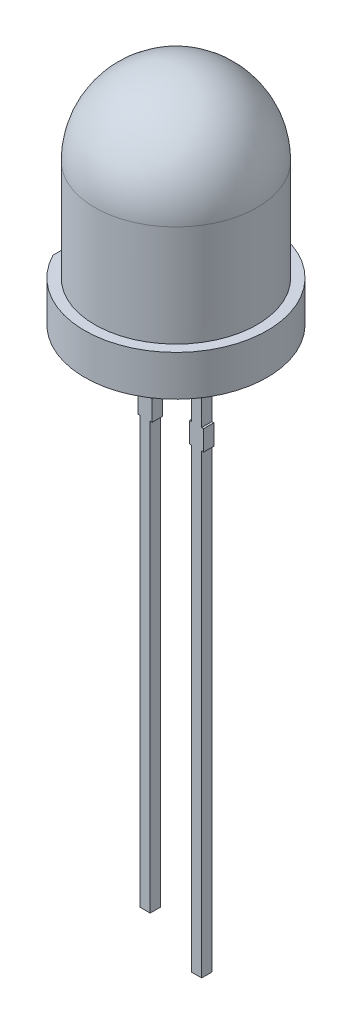
from build123d import *

# Parameters (mm, degrees)
EXTRUDE2_DEPTH     = 2
SKETCH3_3_W        = 0.5
SKETCH3_3_H        = 3.5
SKETCH3_3_H_2      = 1
SKETCH3_3_H_3      = 21
SKETCH3_3_W_2      = 0.1
SKETCH3_3_H_4      = 22.5
EXTRUDE4_DEPTH     = 0.25
CUT_EXTRUDE1_DEPTH = 0.01


with BuildPart() as part:
    # Sketch2 → Extrude2 (new body)
    with BuildSketch(Plane(origin=(0, 0, 0), x_dir=(1, 0, 0), z_dir=(0, 1, 0))):
        with BuildLine():
            ThreePointArc((4.5, 0), (1.060660172, 4.373213921), (-4, 2.061552813))
            Line((-4, 2.061552813), (-4, -2.061552813))
            ThreePointArc((-4, -2.061552813), (1.060660172, -4.373213921), (4.5, 0))
        make_face()
    extrude(amount=EXTRUDE2_DEPTH)

    # Sketch3 → Revolve1 (revolve)
    with BuildSketch(Plane.XY, mode=Mode.PRIVATE) as revolve1_sk:
        with BuildLine():
            Line((0, 11), (0, 2))
            Line((0, 2), (4, 2))
            Line((4, 2), (4, 7))
            ThreePointArc((4, 7), (2.828427125, 9.828427125), (0, 11))
        make_face()
    revolve(revolve1_sk.sketch.rotate(Axis((0, 2, 0), (0, 1, 0)), 180), axis=Axis((0, 2, 0), (0, 1, 0)))  # turned: the seam where the file's is

    # Sketch3_3 → Extrude4 (add, symmetric)
    with BuildSketch(Plane.XY):
        with Locations((-1.27, -1.75)):
            Rectangle(SKETCH3_3_W, SKETCH3_3_H)
        with Locations((-1.27, -4)):
            Rectangle(SKETCH3_3_W, SKETCH3_3_H_2)
        with Locations((-1.27, -15)):
            Rectangle(SKETCH3_3_W, SKETCH3_3_H_3)
        with Locations((-0.97, -4)):
            Rectangle(SKETCH3_3_W_2, SKETCH3_3_H_2)
        with Locations((-1.57, -4)):
            Rectangle(SKETCH3_3_W_2, SKETCH3_3_H_2)
        with Locations((1.27, -1.75)):
            Rectangle(SKETCH3_3_W, SKETCH3_3_H)
        with Locations((1.27, -4)):
            Rectangle(SKETCH3_3_W, SKETCH3_3_H_2)
        with Locations((0.97, -4)):
            Rectangle(SKETCH3_3_W_2, SKETCH3_3_H_2)
        with Locations((1.57, -4)):
            Rectangle(SKETCH3_3_W_2, SKETCH3_3_H_2)
        with Locations((1.27, -15.75)):
            Rectangle(SKETCH3_3_W, SKETCH3_3_H_4)
    extrude(amount=EXTRUDE4_DEPTH, both=True)

    # Sketch5 → Cut-Extrude1 (cut)
    with BuildSketch(Plane.XZ):
        Polygon((-0.452420052, 0.048021614), (-0.47417486, -0.025055309), (-0.490430869, -0.025055309), (-0.502660437, 0.025876182), (-0.516542648, -0.025055309), (-0.532708513, -0.025055309), (-0.554343129, 0.048021614), (-0.535593129, 0.048021614), (-0.524625581, -0.004802905), (-0.511554667, 0.048021614), (-0.493375581, 0.048021614), (-0.481957312, -0.004802905), (-0.471260196, 0.048021614), align=None)
        Polygon((-0.352420052, 0.048021614), (-0.37417486, -0.025055309), (-0.390430869, -0.025055309), (-0.402660437, 0.025876182), (-0.416542648, -0.025055309), (-0.432708513, -0.025055309), (-0.454343129, 0.048021614), (-0.435593129, 0.048021614), (-0.424625581, -0.004802905), (-0.411554667, 0.048021614), (-0.393375581, 0.048021614), (-0.381957312, -0.004802905), (-0.371260196, 0.048021614), align=None)
        Polygon((-0.252420052, 0.048021614), (-0.27417486, -0.025055309), (-0.290430869, -0.025055309), (-0.302660437, 0.025876182), (-0.316542648, -0.025055309), (-0.332708513, -0.025055309), (-0.354343129, 0.048021614), (-0.335593129, 0.048021614), (-0.324625581, -0.004802905), (-0.311554667, 0.048021614), (-0.293375581, 0.048021614), (-0.281957312, -0.004802905), (-0.271260196, 0.048021614), align=None)
        with BuildLine():
            add(Edge.make_bspline(
                [(-0.212035437, -0.012555309), (-0.21208492, -0.013262166), (-0.212187706, -0.014730447), (-0.212956, -0.016874826), (-0.214094784, -0.018983863), (-0.215732268, -0.020904006), (-0.217829848, -0.022583896), (-0.220340975, -0.023963628), (-0.223281261, -0.024900598), (-0.225379574, -0.025002772), (-0.226458513, -0.025055309)],
                knots=[0, 0, 0, 0, 0.803957419, 1.669978378, 2.568830098, 3.52434643, 4.522321038, 5.61514242, 6.773720829, 8, 8, 8, 8], degree=3))
            add(Edge.make_bspline(
                [(-0.226458513, -0.025055309), (-0.227295736, -0.025011774), (-0.228974504, -0.02492448), (-0.231369549, -0.024136875), (-0.233543605, -0.022973736), (-0.235415737, -0.021424559), (-0.23687457, -0.0195154), (-0.238084154, -0.017418687), (-0.238823189, -0.015046255), (-0.238913083, -0.013391561), (-0.238958513, -0.012555309)],
                knots=[0, 0, 0, 0, 1.021956945, 2.049191568, 3.052757421, 4.027239216, 4.995768388, 5.977850542, 6.978043055, 8, 8, 8, 8], degree=3))
            add(Edge.make_bspline(
                [(-0.238958513, -0.012555309), (-0.238915219, -0.011718138), (-0.238830047, -0.010071215), (-0.238068233, -0.007725366), (-0.236922057, -0.005616645), (-0.235421881, -0.003749514), (-0.233582941, -0.002149972), (-0.231367358, -0.001022273), (-0.228981648, -0.000175477), (-0.227297097, -9.5248e-05), (-0.226458513, -5.5309e-05)],
                knots=[0, 0, 0, 0, 1.02256761, 2.011643391, 2.988402578, 3.947919371, 4.930894396, 5.945859716, 6.97743239, 8, 8, 8, 8], degree=3))
            add(Edge.make_bspline(
                [(-0.226458513, -5.5309e-05), (-0.225407874, -0.000105392), (-0.223333207, -0.000204291), (-0.220436843, -0.001211105), (-0.217835951, -0.002501965), (-0.2157626, -0.004261522), (-0.214091645, -0.00616548), (-0.212920275, -0.008245116), (-0.212192959, -0.010395053), (-0.212086927, -0.011849177), (-0.212035437, -0.012555309)],
                knots=[0, 0, 0, 0, 1.193718436, 2.357200027, 3.46616707, 4.488721408, 5.436751473, 6.342315378, 7.195018269, 8, 8, 8, 8], degree=3))
        make_face()
        with BuildLine():
            add(Edge.make_bspline(
                [(-0.151698898, -0.026978386), (-0.153413167, -0.026955925), (-0.156728772, -0.026912483), (-0.161533335, -0.026397716), (-0.166014281, -0.025688356), (-0.170154861, -0.024595527), (-0.173959709, -0.023220375), (-0.17743498, -0.021541535), (-0.180652214, -0.019674828), (-0.183508823, -0.017451603), (-0.186067786, -0.015034575), (-0.188287436, -0.012370522), (-0.190222924, -0.009528525), (-0.191813015, -0.006401934), (-0.193053627, -0.002961141), (-0.193933091, 0.000862934), (-0.194544404, 0.005074496), (-0.194665015, 0.008025352), (-0.194727744, 0.009560076)],
                knots=[0, 0, 0, 0, 1.28338536, 2.482222902, 3.615641418, 4.678302996, 5.684574369, 6.640891817, 7.565949061, 8.464746586, 9.345581526, 10.197575617, 11.056903422, 11.91580542, 12.817603529, 13.789275343, 14.850214295, 16, 16, 16, 16], degree=3))
            Line((-0.194727744, 0.009560076), (-0.175707312, 0.009560076))
            add(Edge.make_bspline(
                [(-0.175707312, 0.009560076), (-0.175585191, 0.00833566), (-0.17535482, 0.006025895), (-0.1747581, 0.002809491), (-0.174006085, 3.4372e-05), (-0.172988015, -0.002292557), (-0.171830096, -0.004277646), (-0.17053807, -0.006010276), (-0.169182565, -0.00757185), (-0.167200639, -0.009343817), (-0.164429187, -0.011107943), (-0.160714991, -0.012570541), (-0.156621271, -0.013372196), (-0.153775677, -0.013467447), (-0.15229986, -0.013516847)],
                knots=[0, 0, 0, 0, 1.193967772, 2.252326225, 3.172507138, 3.978093684, 4.710151129, 5.398551009, 6.073569162, 6.713873795, 7.973381569, 9.239028936, 10.568070259, 12, 12, 12, 12], degree=3))
            add(Edge.make_bspline(
                [(-0.15229986, -0.013516847), (-0.150733021, -0.013472719), (-0.147766038, -0.013389158), (-0.143584285, -0.012560669), (-0.139942179, -0.011270051), (-0.136876202, -0.009450885), (-0.13443239, -0.007203356), (-0.13259409, -0.004598186), (-0.131448613, -0.00157605), (-0.131328354, 0.000575561), (-0.131266206, 0.00168748)],
                knots=[0, 0, 0, 0, 1.292881893, 2.448216373, 3.505729005, 4.47062867, 5.372299035, 6.228402631, 7.084466243, 8, 8, 8, 8], degree=3))
            add(Edge.make_bspline(
                [(-0.131266206, 0.00168748), (-0.13131971, 0.002807024), (-0.131419031, 0.004885282), (-0.132257529, 0.007330253), (-0.133305602, 0.008952137), (-0.13429607, 0.010086044), (-0.135527892, 0.011158151), (-0.137010698, 0.0121395), (-0.13875981, 0.013072394), (-0.140758987, 0.014004298), (-0.143064778, 0.014867152), (-0.145655772, 0.015704135), (-0.14856173, 0.016528433), (-0.151770701, 0.017462566), (-0.155354627, 0.01829539), (-0.157849184, 0.018893448), (-0.159150821, 0.019205509)],
                knots=[0, 0, 0, 0, 1.308217091, 2.428499093, 2.971811445, 3.562083625, 4.185450824, 4.878313926, 5.639298351, 6.505129032, 7.459166185, 8.51991211, 9.692741175, 10.996059842, 12.432571982, 14, 14, 14, 14], degree=3))
            add(Edge.make_bspline(
                [(-0.159150821, 0.019205509), (-0.160434916, 0.019517892), (-0.162923518, 0.020123298), (-0.166538646, 0.021145274), (-0.16990111, 0.022285748), (-0.173053637, 0.02347522), (-0.175944419, 0.024800582), (-0.178595499, 0.026230563), (-0.180971013, 0.027798133), (-0.183098078, 0.029449077), (-0.184954397, 0.031240034), (-0.186557798, 0.033174297), (-0.187915436, 0.035247743), (-0.189013762, 0.03747798), (-0.189850499, 0.039860473), (-0.190451668, 0.042408203), (-0.19081621, 0.04511641), (-0.190859464, 0.046978797), (-0.19088159, 0.04793147)],
                knots=[0, 0, 0, 0, 1.350138021, 2.616595417, 3.836558268, 4.976793827, 6.057431512, 7.083186274, 8.051004732, 8.961973241, 9.830394181, 10.680720399, 11.523687559, 12.356594861, 13.21427804, 14.097880016, 15.027001965, 16, 16, 16, 16], degree=3))
            add(Edge.make_bspline(
                [(-0.19088159, 0.04793147), (-0.190842157, 0.048964648), (-0.190764395, 0.051002064), (-0.190291881, 0.053995248), (-0.189427661, 0.056853586), (-0.188256929, 0.059584082), (-0.186790457, 0.062168959), (-0.185017518, 0.064562502), (-0.183012479, 0.06678559), (-0.180732718, 0.068816516), (-0.178209425, 0.070636258), (-0.17546477, 0.072278331), (-0.172464942, 0.073651759), (-0.169251563, 0.074824306), (-0.165834335, 0.07575158), (-0.162246308, 0.076407135), (-0.158509007, 0.076808345), (-0.155966743, 0.076847734), (-0.154673658, 0.076867768)],
                knots=[0, 0, 0, 0, 0.957814223, 1.888799201, 2.799332819, 3.718439235, 4.637311203, 5.547134667, 6.473851604, 7.407471124, 8.371205588, 9.353539842, 10.366965553, 11.424217362, 12.520959394, 13.644407811, 14.801862002, 16, 16, 16, 16], degree=3))
            add(Edge.make_bspline(
                [(-0.154673658, 0.076867768), (-0.153220801, 0.076833322), (-0.150369959, 0.076765731), (-0.146174857, 0.076399734), (-0.142176274, 0.075651708), (-0.138343346, 0.074705992), (-0.13472451, 0.073480535), (-0.131328822, 0.072007379), (-0.128197886, 0.070266279), (-0.125346485, 0.068272367), (-0.122751207, 0.066122146), (-0.120477296, 0.063775803), (-0.118578546, 0.061230281), (-0.116980115, 0.058506658), (-0.115676946, 0.055491026), (-0.114777074, 0.052078406), (-0.1141769, 0.048261336), (-0.114033588, 0.045580047), (-0.113958513, 0.044175461)],
                knots=[0, 0, 0, 0, 1.186950675, 2.32907279, 3.434719709, 4.506181443, 5.551366779, 6.551492465, 7.525684865, 8.472032948, 9.389619293, 10.274870494, 11.133875947, 11.977154569, 12.849419986, 13.808029842, 14.851741326, 16, 16, 16, 16], degree=3))
            Line((-0.113958513, 0.044175461), (-0.133039042, 0.044175461))
            add(Edge.make_bspline(
                [(-0.133039042, 0.044175461), (-0.133232135, 0.04568679), (-0.133598882, 0.048557313), (-0.134860455, 0.052540527), (-0.136712759, 0.055909158), (-0.139102739, 0.058710357), (-0.142100521, 0.060848038), (-0.145645189, 0.06235808), (-0.149721752, 0.063255245), (-0.152615614, 0.063354298), (-0.154132792, 0.06340623)],
                knots=[0, 0, 0, 0, 1.138878594, 2.163113395, 3.106118689, 3.999005743, 4.895818561, 5.835958478, 6.865448045, 8, 8, 8, 8], degree=3))
            add(Edge.make_bspline(
                [(-0.154132792, 0.06340623), (-0.155457094, 0.063358427), (-0.157963751, 0.063267945), (-0.16151172, 0.062642234), (-0.164557384, 0.061451012), (-0.167151877, 0.059865681), (-0.169195601, 0.057772413), (-0.1706415, 0.055206604), (-0.171532341, 0.052206069), (-0.171610101, 0.050051404), (-0.171650821, 0.048923057)],
                knots=[0, 0, 0, 0, 1.229005574, 2.326279772, 3.32381644, 4.246881527, 5.127569263, 6.005949281, 6.955762047, 8, 8, 8, 8], degree=3))
            add(Edge.make_bspline(
                [(-0.171650821, 0.048923057), (-0.171610322, 0.047897965), (-0.171536111, 0.046019596), (-0.170870004, 0.043425554), (-0.16958966, 0.04138104), (-0.16781125, 0.039663814), (-0.165285794, 0.03831158), (-0.162026843, 0.036959297), (-0.157856304, 0.035663337), (-0.154748664, 0.034910972), (-0.153051062, 0.03449998)],
                knots=[0, 0, 0, 0, 0.944171751, 1.730091105, 2.434406385, 3.13926556, 3.982880664, 5.054072901, 6.39073578, 8, 8, 8, 8], degree=3))
            add(Edge.make_bspline(
                [(-0.153051062, 0.03449998), (-0.151014154, 0.034064746), (-0.147157256, 0.033240629), (-0.141746716, 0.031836536), (-0.136957893, 0.030503339), (-0.134007267, 0.02952282), (-0.132618369, 0.029061278)],
                knots=[0, 0, 0, 0, 1.181242773, 2.236690395, 3.169987357, 4, 4, 4, 4], degree=3))
            add(Edge.make_bspline(
                [(-0.132618369, 0.029061278), (-0.131091376, 0.028442155), (-0.128192164, 0.027266663), (-0.124226105, 0.025066822), (-0.120766343, 0.022527555), (-0.117777924, 0.019546082), (-0.115278962, 0.016105896), (-0.11345, 0.012226316), (-0.112247752, 0.007987528), (-0.112107235, 0.005031062), (-0.112035437, 0.003520412)],
                knots=[0, 0, 0, 0, 1.12559323, 2.137097481, 3.091563588, 4.050170991, 5.011659374, 5.982488114, 6.969123197, 8, 8, 8, 8], degree=3))
            add(Edge.make_bspline(
                [(-0.112035437, 0.003520412), (-0.112067433, 0.002485834), (-0.112130635, 0.000442263), (-0.11271938, -0.002574668), (-0.113554226, -0.005529335), (-0.114858464, -0.008345934), (-0.116387927, -0.011068918), (-0.118336392, -0.013560538), (-0.120477231, -0.015953403), (-0.122964789, -0.018123223), (-0.125736976, -0.020062402), (-0.128771828, -0.021835888), (-0.132105674, -0.023339503), (-0.135673084, -0.024667505), (-0.139448786, -0.025725713), (-0.143405833, -0.026421654), (-0.147500615, -0.026898327), (-0.150285229, -0.026951428), (-0.151698898, -0.026978386)],
                knots=[0, 0, 0, 0, 0.891235748, 1.760430872, 2.64325458, 3.532604557, 4.430471646, 5.330579775, 6.253890478, 7.196515965, 8.169562172, 9.16815398, 10.223350337, 11.319304113, 12.44891929, 13.599348363, 14.781258036, 16, 16, 16, 16], degree=3))
        make_face()
        with BuildLine():
            add(Edge.make_bspline(
                [(-0.054343129, -0.017363001), (-0.05479239, -0.018128605), (-0.055673843, -0.019630724), (-0.057357378, -0.021621486), (-0.05933421, -0.023285318), (-0.06158589, -0.02464937), (-0.064108841, -0.02570284), (-0.066907588, -0.0264493), (-0.06997362, -0.026898682), (-0.072109985, -0.026951241), (-0.073213321, -0.026978386)],
                knots=[0, 0, 0, 0, 0.951672298, 1.867185576, 2.782698853, 3.71392514, 4.682455292, 5.707525699, 6.816041397, 8, 8, 8, 8], degree=3))
            add(Edge.make_bspline(
                [(-0.073213321, -0.026978386), (-0.074235459, -0.026950599), (-0.076224072, -0.026896538), (-0.079113577, -0.026614606), (-0.081796867, -0.026066823), (-0.084292411, -0.025325462), (-0.086569039, -0.02432367), (-0.088681538, -0.023151303), (-0.090576196, -0.021731714), (-0.092274919, -0.020098848), (-0.093755869, -0.018241847), (-0.095047787, -0.016183116), (-0.096182518, -0.013921019), (-0.097027894, -0.011404515), (-0.097720507, -0.008692489), (-0.0982298, -0.005770269), (-0.098532477, -0.002635898), (-0.098559814, -0.000476678), (-0.098573898, 0.000635797)],
                knots=[0, 0, 0, 0, 1.141517227, 2.220869849, 3.236285704, 4.194941571, 5.121491616, 6.007825957, 6.886792942, 7.75675051, 8.631724762, 9.531432414, 10.466647329, 11.449839378, 12.488631973, 13.589891555, 14.758261493, 16, 16, 16, 16], degree=3))
            Line((-0.098573898, 0.000635797), (-0.098573898, 0.048021614))
            Line((-0.098573898, 0.048021614), (-0.079343129, 0.048021614))
            Line((-0.079343129, 0.048021614), (-0.079343129, 0.000725941))
            add(Edge.make_bspline(
                [(-0.079343129, 0.000725941), (-0.079313293, -0.000596845), (-0.079259113, -0.002999002), (-0.078913279, -0.006254611), (-0.078253986, -0.008789883), (-0.077317819, -0.010704467), (-0.076025305, -0.012012497), (-0.074511171, -0.012902138), (-0.072735319, -0.013422068), (-0.071474126, -0.013484137), (-0.070809475, -0.013516847)],
                knots=[0, 0, 0, 0, 1.670420621, 3.033453265, 4.122593961, 4.965404288, 5.689746319, 6.409770491, 7.161946514, 8, 8, 8, 8], degree=3))
            add(Edge.make_bspline(
                [(-0.070809475, -0.013516847), (-0.070065659, -0.013490209), (-0.06857237, -0.01343673), (-0.06636875, -0.012928717), (-0.064213248, -0.012133772), (-0.062096287, -0.011059432), (-0.060076433, -0.009606203), (-0.05808979, -0.00789237), (-0.056149344, -0.005857843), (-0.054960827, -0.00433325), (-0.054343129, -0.003540886)],
                knots=[0, 0, 0, 0, 0.891993808, 1.790772165, 2.70010969, 3.646775564, 4.631044069, 5.679839113, 6.794162298, 8, 8, 8, 8], degree=3))
            Line((-0.054343129, -0.003540886), (-0.054343129, 0.048021614))
            Line((-0.054343129, 0.048021614), (-0.03511236, 0.048021614))
            Line((-0.03511236, 0.048021614), (-0.03511236, -0.025055309))
            Line((-0.03511236, -0.025055309), (-0.054343129, -0.025055309))
            Line((-0.054343129, -0.025055309), (-0.054343129, -0.017363001))
        make_face()
        with BuildLine():
            add(Edge.make_bspline(
                [(-0.000496975, 0.040329307), (-9.8886e-05, 0.041094325), (0.000678985, 0.042589178), (0.002208819, 0.044561834), (0.003967979, 0.046239767), (0.005979323, 0.047605768), (0.008239248, 0.04867154), (0.010743656, 0.049404996), (0.013488277, 0.049869699), (0.015396444, 0.049919013), (0.016390044, 0.049944691)],
                knots=[0, 0, 0, 0, 1.00143585, 1.95681651, 2.888024611, 3.818649522, 4.772323889, 5.782194879, 6.845168342, 8, 8, 8, 8], degree=3))
            add(Edge.make_bspline(
                [(0.016390044, 0.049944691), (0.017492274, 0.049917074), (0.019630758, 0.049863493), (0.022739627, 0.049580562), (0.02563164, 0.049030954), (0.028329249, 0.048298614), (0.030791045, 0.047286341), (0.033077192, 0.046138228), (0.035101396, 0.04468892), (0.036949355, 0.043079827), (0.038551496, 0.041219009), (0.039941538, 0.039161234), (0.041123266, 0.036883648), (0.042076656, 0.034380742), (0.042823403, 0.031663396), (0.043368564, 0.028739558), (0.043652829, 0.025601335), (0.043706261, 0.023442789), (0.043733794, 0.022330509)],
                knots=[0, 0, 0, 0, 1.186832343, 2.3026268, 3.355761513, 4.352522852, 5.305579363, 6.217046986, 7.099481147, 7.977887867, 8.849185092, 9.734381594, 10.645849217, 11.604985507, 12.612131568, 13.675865719, 14.802392456, 16, 16, 16, 16], degree=3))
            Line((0.043733794, 0.022330509), (0.043733794, -0.025055309))
            Line((0.043733794, -0.025055309), (0.024503025, -0.025055309))
            Line((0.024503025, -0.025055309), (0.024503025, 0.022240364))
            add(Edge.make_bspline(
                [(0.024503025, 0.022240364), (0.02447805, 0.023473695), (0.024431956, 0.025749847), (0.024014762, 0.028868703), (0.023258836, 0.031395993), (0.022153217, 0.033366881), (0.020664438, 0.034849916), (0.018744365, 0.035795409), (0.016478903, 0.036417555), (0.014832409, 0.036460368), (0.01395615, 0.036483153)],
                knots=[0, 0, 0, 0, 1.441015903, 2.659442997, 3.666423338, 4.505664336, 5.275500286, 6.081849636, 6.979166905, 8, 8, 8, 8], degree=3))
            add(Edge.make_bspline(
                [(0.01395615, 0.036483153), (0.013382974, 0.036450966), (0.012221845, 0.036385764), (0.010462077, 0.035942437), (0.008704486, 0.035176712), (0.006903948, 0.034132481), (0.005085389, 0.032799231), (0.003201166, 0.031207783), (0.001356329, 0.029256019), (0.000138187, 0.027844267), (-0.000496975, 0.027108153)],
                knots=[0, 0, 0, 0, 0.774464777, 1.568897174, 2.436202086, 3.357883609, 4.375901529, 5.479906668, 6.685976861, 8, 8, 8, 8], degree=3))
            Line((-0.000496975, 0.027108153), (-0.000496975, -0.025055309))
            Line((-0.000496975, -0.025055309), (-0.019727744, -0.025055309))
            Line((-0.019727744, -0.025055309), (-0.019727744, 0.048021614))
            Line((-0.019727744, 0.048021614), (-0.000496975, 0.048021614))
            Line((-0.000496975, 0.048021614), (-0.000496975, 0.040329307))
        make_face()
        Polygon((0.128349179, -0.025055309), (0.061041487, -0.025055309), (0.061041487, 0.074944691), (0.080272256, 0.074944691), (0.080272256, -0.01159377), (0.128349179, -0.01159377), align=None)
        Polygon((0.218733794, -0.025055309), (0.13988764, -0.025055309), (0.13988764, 0.074944691), (0.216810717, 0.074944691), (0.216810717, 0.061483153), (0.15911841, 0.061483153), (0.15911841, 0.032636999), (0.212964563, 0.032636999), (0.212964563, 0.019175461), (0.15911841, 0.019175461), (0.15911841, -0.01159377), (0.218733794, -0.01159377), align=None)
        with BuildLine():
            add(Edge.make_bspline(
                [(0.320656871, 0.025485557), (0.320619382, 0.023440568), (0.320546786, 0.019480462), (0.319905419, 0.013731125), (0.318863002, 0.008383433), (0.317437315, 0.003407415), (0.31553627, -0.00115789), (0.313207614, -0.005323596), (0.310506555, -0.009133738), (0.307298891, -0.012469281), (0.303746771, -0.015494877), (0.29970166, -0.018024958), (0.29529937, -0.020248007), (0.290442705, -0.02201087), (0.285178972, -0.02337715), (0.27950258, -0.024370282), (0.273412411, -0.024926811), (0.269215681, -0.025011584), (0.267051102, -0.025055309)],
                knots=[0, 0, 0, 0, 1.161219646, 2.24869368, 3.280708715, 4.252829228, 5.183621711, 6.082630713, 6.958888302, 7.828118733, 8.704376322, 9.602322718, 10.530939534, 11.501077163, 12.530454616, 13.6163204, 14.770551419, 16, 16, 16, 16], degree=3))
            Line((0.267051102, -0.025055309), (0.23411841, -0.025055309))
            Line((0.23411841, -0.025055309), (0.23411841, 0.074944691))
            Line((0.23411841, 0.074944691), (0.267051102, 0.074944691))
            add(Edge.make_bspline(
                [(0.267051102, 0.074944691), (0.269216229, 0.07491825), (0.273415268, 0.074866968), (0.279497784, 0.074239794), (0.285177252, 0.073299329), (0.290443899, 0.071964383), (0.295279551, 0.070211312), (0.299719365, 0.068111307), (0.303720875, 0.065584081), (0.30732052, 0.062666896), (0.310483394, 0.059356428), (0.313210128, 0.055639717), (0.315534721, 0.051559476), (0.317438524, 0.0470852), (0.318854383, 0.042216259), (0.319912989, 0.036981711), (0.32054327, 0.031360312), (0.320618297, 0.027480366), (0.320656871, 0.025485557)],
                knots=[0, 0, 0, 0, 1.24197401, 2.408678741, 3.504780762, 4.5433438, 5.521527764, 6.452152268, 7.356290842, 8.230615943, 9.104657617, 9.976030571, 10.869306848, 11.793823342, 12.759447772, 13.773938722, 14.855507726, 16, 16, 16, 16], degree=3))
        make_face()
        with BuildLine():
            add(Edge.make_bspline(
                [(0.301426102, 0.025515605), (0.301415887, 0.026898717), (0.301396016, 0.029589109), (0.301037723, 0.033508742), (0.300549108, 0.037215704), (0.299821565, 0.040697771), (0.298933333, 0.043961832), (0.297672577, 0.046918339), (0.296211989, 0.049635016), (0.294416506, 0.05204704), (0.292343593, 0.054239903), (0.289889401, 0.056121069), (0.28708846, 0.057766657), (0.283902739, 0.059109051), (0.280329969, 0.060192615), (0.276324606, 0.060969029), (0.27187852, 0.061403294), (0.26876481, 0.061455784), (0.267141246, 0.061483153)],
                knots=[0, 0, 0, 0, 1.149495408, 2.235966294, 3.270011624, 4.256484947, 5.192194903, 6.076854796, 6.922927111, 7.750728226, 8.569431422, 9.423985878, 10.312361613, 11.263690782, 12.291074984, 13.411453686, 14.650268675, 16, 16, 16, 16], degree=3))
            Line((0.267141246, 0.061483153), (0.253349179, 0.061483153))
            Line((0.253349179, 0.061483153), (0.253349179, -0.01159377))
            Line((0.253349179, -0.01159377), (0.267141246, -0.01159377))
            add(Edge.make_bspline(
                [(0.267141246, -0.01159377), (0.268775215, -0.011570535), (0.271900731, -0.011526091), (0.276352934, -0.011040712), (0.280349851, -0.010275816), (0.283903927, -0.009203809), (0.287044032, -0.007801686), (0.289821678, -0.006139797), (0.292303201, -0.004250769), (0.294388868, -0.002014133), (0.296182011, 0.000482109), (0.297688388, 0.003257542), (0.298882913, 0.006334262), (0.299839003, 0.009675113), (0.300546544, 0.013286511), (0.301042097, 0.017151641), (0.301394092, 0.021252344), (0.301415267, 0.024072507), (0.301426102, 0.025515605)],
                knots=[0, 0, 0, 0, 1.33477961, 2.553215293, 3.654392007, 4.656342135, 5.579650195, 6.456971844, 7.296880229, 8.119053426, 8.945898676, 9.802940951, 10.692095258, 11.637628976, 12.639278173, 13.696155562, 14.821106832, 16, 16, 16, 16], degree=3))
        make_face(mode=Mode.SUBTRACT)
        with BuildLine():
            add(Edge.make_bspline(
                [(0.366810717, -0.012555309), (0.366761234, -0.013262166), (0.366658448, -0.014730447), (0.365890153, -0.016874826), (0.36475137, -0.018983863), (0.363113886, -0.020904006), (0.361016306, -0.022583896), (0.358505179, -0.023963628), (0.355564893, -0.024900598), (0.35346658, -0.025002772), (0.35238764, -0.025055309)],
                knots=[0, 0, 0, 0, 0.803957419, 1.669978378, 2.568830098, 3.52434643, 4.522321038, 5.61514242, 6.773720829, 8, 8, 8, 8], degree=3))
            add(Edge.make_bspline(
                [(0.35238764, -0.025055309), (0.351550418, -0.025011774), (0.34987165, -0.02492448), (0.347476605, -0.024136875), (0.345302549, -0.022973736), (0.343430417, -0.021424559), (0.341971584, -0.0195154), (0.340761999, -0.017418687), (0.340022965, -0.015046255), (0.339933071, -0.013391561), (0.33988764, -0.012555309)],
                knots=[0, 0, 0, 0, 1.021956945, 2.049191568, 3.052757421, 4.027239216, 4.995768388, 5.977850542, 6.978043055, 8, 8, 8, 8], degree=3))
            add(Edge.make_bspline(
                [(0.33988764, -0.012555309), (0.339930935, -0.011718138), (0.340016107, -0.010071215), (0.34077792, -0.007725366), (0.341924096, -0.005616645), (0.343424272, -0.003749514), (0.345263212, -0.002149972), (0.347478796, -0.001022273), (0.349864506, -0.000175477), (0.351549057, -9.5248e-05), (0.35238764, -5.5309e-05)],
                knots=[0, 0, 0, 0, 1.02256761, 2.011643391, 2.988402578, 3.947919371, 4.930894396, 5.945859716, 6.97743239, 8, 8, 8, 8], degree=3))
            add(Edge.make_bspline(
                [(0.35238764, -5.5309e-05), (0.35343828, -0.000105392), (0.355512947, -0.000204291), (0.358409311, -0.001211105), (0.361010203, -0.002501965), (0.363083554, -0.004261522), (0.364754509, -0.00616548), (0.365925879, -0.008245116), (0.366653194, -0.010395053), (0.366759227, -0.011849177), (0.366810717, -0.012555309)],
                knots=[0, 0, 0, 0, 1.193718436, 2.357200027, 3.46616707, 4.488721408, 5.436751473, 6.342315378, 7.195018269, 8, 8, 8, 8], degree=3))
        make_face()
        with BuildLine():
            add(Edge.make_bspline(
                [(0.417261438, -0.026978386), (0.415977066, -0.026957726), (0.41345764, -0.026917199), (0.409776073, -0.026355736), (0.406237891, -0.025617912), (0.402904955, -0.024452621), (0.399767845, -0.023031513), (0.39688409, -0.021247624), (0.39419848, -0.019223983), (0.39178997, -0.016851591), (0.389615744, -0.014223551), (0.387683062, -0.011328598), (0.386034923, -0.008160311), (0.384649419, -0.004739798), (0.383523944, -0.001064719), (0.382769705, 0.002884919), (0.382264229, 0.007093044), (0.382218779, 0.009989165), (0.382195333, 0.011483153)],
                knots=[0, 0, 0, 0, 1.047336758, 2.054456287, 3.03439317, 3.993646679, 4.930156219, 5.840202366, 6.755960155, 7.669488798, 8.592807151, 9.536144313, 10.505277466, 11.502793093, 12.545139458, 13.637098113, 14.781077921, 16, 16, 16, 16], degree=3))
            add(Edge.make_bspline(
                [(0.382195333, 0.011483153), (0.382219785, 0.012946975), (0.38226749, 0.015802863), (0.382766159, 0.019962383), (0.383537291, 0.023884283), (0.384616354, 0.027569172), (0.386006421, 0.031005361), (0.387647256, 0.034191256), (0.389564722, 0.037107772), (0.391717343, 0.039770346), (0.39417872, 0.0421034), (0.396822351, 0.044218681), (0.399761776, 0.045945596), (0.402901748, 0.047395506), (0.40624303, 0.048543551), (0.409771263, 0.049332693), (0.413458333, 0.0498806), (0.4159773, 0.04992305), (0.417261438, 0.049944691)],
                knots=[0, 0, 0, 0, 1.194867585, 2.331162469, 3.415519797, 4.45592294, 5.461402785, 6.438161706, 7.377349552, 8.307339102, 9.227093374, 10.141741913, 11.066139606, 12.003009567, 12.962632249, 13.944753045, 14.952260169, 16, 16, 16, 16], degree=3))
            add(Edge.make_bspline(
                [(0.417261438, 0.049944691), (0.418313979, 0.049919672), (0.420404129, 0.049869989), (0.423487179, 0.049532527), (0.426493284, 0.048995345), (0.429388011, 0.04821995), (0.432155679, 0.047221068), (0.434767023, 0.046063656), (0.437196447, 0.044702611), (0.439421138, 0.043141438), (0.441436051, 0.04139131), (0.443259277, 0.039489182), (0.444851311, 0.037414008), (0.446237363, 0.035145247), (0.44738925, 0.032614596), (0.448313899, 0.029739403), (0.449069866, 0.026515442), (0.449354795, 0.02421723), (0.449503025, 0.023021614)],
                knots=[0, 0, 0, 0, 1.080765488, 2.146200892, 3.181163785, 4.214080283, 5.219383685, 6.200022783, 7.144110219, 8.074369293, 8.985844923, 9.880687245, 10.775588676, 11.666402291, 12.605320916, 13.623381954, 14.763593765, 16, 16, 16, 16], degree=3))
            Line((0.449503025, 0.023021614), (0.4303624, 0.023021614))
            add(Edge.make_bspline(
                [(0.4303624, 0.023021614), (0.430271241, 0.024189479), (0.43010145, 0.026364739), (0.429295269, 0.029320699), (0.428099295, 0.031757154), (0.426385576, 0.033566054), (0.424372279, 0.034869099), (0.422152814, 0.035801838), (0.419716071, 0.036396797), (0.41801618, 0.036453809), (0.417141246, 0.036483153)],
                knots=[0, 0, 0, 0, 1.312413462, 2.444497233, 3.420095611, 4.326995713, 5.203269489, 6.094987921, 7.019489993, 8, 8, 8, 8], degree=3))
            add(Edge.make_bspline(
                [(0.417141246, 0.036483153), (0.416120505, 0.03643537), (0.41412013, 0.036341727), (0.411755632, 0.035472027), (0.410001624, 0.034523682), (0.408770919, 0.03353154), (0.407566261, 0.032352503), (0.406395514, 0.030974359), (0.405294969, 0.029365246), (0.404352668, 0.027498293), (0.403513872, 0.025403031), (0.402755731, 0.023090549), (0.402158966, 0.020538033), (0.401749272, 0.017733599), (0.401472215, 0.014693807), (0.401441792, 0.012575561), (0.401426102, 0.011483153)],
                knots=[0, 0, 0, 0, 1.294790379, 2.537435469, 3.165661086, 3.829164872, 4.541864701, 5.311227921, 6.128593511, 7.018685834, 7.968657266, 9.00144956, 10.115435461, 11.302621323, 12.608924514, 14, 14, 14, 14], degree=3))
            add(Edge.make_bspline(
                [(0.401426102, 0.011483153), (0.401445183, 0.010381013), (0.401482005, 0.008254132), (0.401711923, 0.005191367), (0.402131129, 0.00236847), (0.402723536, -0.000204261), (0.403475279, -0.002534694), (0.404359646, -0.004614908), (0.405292653, -0.006490649), (0.406709767, -0.00855033), (0.408616737, -0.010636668), (0.411246044, -0.012377238), (0.414116625, -0.013368873), (0.416111765, -0.013466482), (0.417141246, -0.013516847)],
                knots=[0, 0, 0, 0, 1.201885478, 2.31936817, 3.346574926, 4.310947528, 5.195171259, 6.012657592, 6.774708936, 7.474495386, 8.733959456, 9.830591055, 10.880597417, 12, 12, 12, 12], degree=3))
            add(Edge.make_bspline(
                [(0.417141246, -0.013516847), (0.418005584, -0.013484501), (0.419682282, -0.013421753), (0.422082952, -0.012872425), (0.42425351, -0.011964583), (0.426177147, -0.010695365), (0.427795395, -0.009038755), (0.428882681, -0.007346434), (0.429559379, -0.005688412), (0.429916941, -0.004083778), (0.430221701, -0.002177365), (0.430332708, -0.000797759), (0.430392448, -5.5309e-05)],
                knots=[0, 0, 0, 0, 1.210933032, 2.349044084, 3.43171645, 4.495267269, 5.558075774, 6.656937348, 7.293383625, 8.059914447, 8.955920865, 10, 10, 10, 10], degree=3))
            Line((0.430392448, -5.5309e-05), (0.449503025, -5.5309e-05))
            add(Edge.make_bspline(
                [(0.449503025, -5.5309e-05), (0.449342642, -0.001270691), (0.449035645, -0.003597123), (0.448282617, -0.006874721), (0.447349068, -0.009793167), (0.446110146, -0.012322886), (0.44471007, -0.014588299), (0.443099609, -0.016645845), (0.441286362, -0.018545256), (0.439283319, -0.020289014), (0.437068527, -0.02182438), (0.434684199, -0.023178986), (0.43212516, -0.024358058), (0.429394727, -0.025307393), (0.426531177, -0.026058221), (0.423549421, -0.026606966), (0.420442187, -0.026895363), (0.418333673, -0.026950399), (0.417261438, -0.026978386)],
                knots=[0, 0, 0, 0, 1.258051893, 2.408109002, 3.448772144, 4.39629231, 5.292354794, 6.178984465, 7.073688607, 7.985023489, 8.900815369, 9.83580737, 10.797563429, 11.78957876, 12.799817111, 13.834620187, 14.898848121, 16, 16, 16, 16], degree=3))
        make_face()
        with BuildLine():
            add(Edge.make_bspline(
                [(0.48988764, 0.049944691), (0.49128176, 0.049911944), (0.494010801, 0.049847839), (0.498005599, 0.049289335), (0.501804428, 0.048399554), (0.505395361, 0.047126911), (0.508747784, 0.045544997), (0.511832098, 0.043675332), (0.514630952, 0.041535187), (0.517090669, 0.039074951), (0.51930261, 0.03639879), (0.521194354, 0.033468483), (0.522806743, 0.0303072), (0.524104056, 0.02691631), (0.52517937, 0.023336742), (0.525873796, 0.019547011), (0.526346845, 0.01558167), (0.526399344, 0.01286683), (0.526426102, 0.011483153)],
                knots=[0, 0, 0, 0, 1.116475797, 2.185542979, 3.224923316, 4.237598129, 5.231919818, 6.189791294, 7.122353009, 8.047287697, 8.971003188, 9.899169676, 10.835865412, 11.808977354, 12.804367075, 13.825779647, 14.891860981, 16, 16, 16, 16], degree=3))
            add(Edge.make_bspline(
                [(0.526426102, 0.011483153), (0.526399377, 0.010079552), (0.526347307, 0.007344887), (0.525878455, 0.003336136), (0.525145035, -0.000467162), (0.524090193, -0.004070124), (0.52272962, -0.007445246), (0.52111196, -0.010611289), (0.519202861, -0.013554796), (0.517011409, -0.016257974), (0.514538397, -0.018716369), (0.511750389, -0.020862641), (0.508654886, -0.022697339), (0.505304174, -0.02425163), (0.501712592, -0.025492999), (0.497923663, -0.026351756), (0.49395861, -0.026872465), (0.491261437, -0.026942641), (0.48988764, -0.026978386)],
                knots=[0, 0, 0, 0, 1.123562633, 2.189060306, 3.227190231, 4.222034994, 5.190106252, 6.137083223, 7.064741556, 7.99416643, 8.918594733, 9.850645887, 10.803851701, 11.794224938, 12.803704333, 13.840687306, 14.900160981, 16, 16, 16, 16], degree=3))
            add(Edge.make_bspline(
                [(0.48988764, -0.026978386), (0.488614095, -0.026952803), (0.486117557, -0.026902655), (0.482463032, -0.026412406), (0.478995129, -0.025595675), (0.475702204, -0.024495869), (0.472629991, -0.023048122), (0.469780352, -0.021290051), (0.46715267, -0.019232053), (0.464743974, -0.016893183), (0.462604381, -0.014250292), (0.46069655, -0.011358764), (0.459089646, -0.008181724), (0.457686084, -0.004776353), (0.45660703, -0.00107936), (0.455847035, 0.002874634), (0.455341362, 0.007093185), (0.455295773, 0.009989213), (0.455272256, 0.011483153)],
                knots=[0, 0, 0, 0, 1.045185112, 2.048882016, 3.020291938, 3.966880199, 4.893905909, 5.802213808, 6.710261089, 7.629080276, 8.552524605, 9.496788192, 10.46774551, 11.471038078, 12.517063969, 13.623413772, 14.774018743, 16, 16, 16, 16], degree=3))
            add(Edge.make_bspline(
                [(0.455272256, 0.011483153), (0.45530007, 0.012946556), (0.455354125, 0.015790549), (0.455803512, 0.019944925), (0.456594472, 0.023848876), (0.457629991, 0.027538506), (0.458995742, 0.030972581), (0.460598758, 0.034169233), (0.462523201, 0.037069397), (0.46465259, 0.039738453), (0.46706526, 0.042115263), (0.469712957, 0.044197218), (0.472600713, 0.045955954), (0.475708828, 0.047393984), (0.47900991, 0.0485388), (0.482496493, 0.049336771), (0.486134699, 0.049878506), (0.488623593, 0.049922399), (0.48988764, 0.049944691)],
                knots=[0, 0, 0, 0, 1.201848745, 2.335685805, 3.426378622, 4.470561871, 5.478866717, 6.457570667, 7.402245833, 8.332481093, 9.257462806, 10.17745529, 11.093170774, 12.028051071, 12.98550063, 13.957333963, 14.96257992, 16, 16, 16, 16], degree=3))
        make_face()
        with BuildLine():
            add(Edge.make_bspline(
                [(0.489947737, -0.013516847), (0.49117871, -0.013443153), (0.493564584, -0.01330032), (0.496946578, -0.012145849), (0.499907414, -0.010220458), (0.501994229, -0.008024084), (0.503398758, -0.005897704), (0.504367947, -0.004046232), (0.505195392, -0.001968184), (0.505927059, 0.000327381), (0.506479391, 0.002843384), (0.506906745, 0.005551397), (0.507139155, 0.008454278), (0.507176191, 0.010451123), (0.507195333, 0.011483153)],
                knots=[0, 0, 0, 0, 1.295059177, 2.510086438, 3.716370727, 4.985576951, 5.670626941, 6.397730367, 7.183741792, 8.025007773, 8.934067091, 9.895485546, 10.912324256, 12, 12, 12, 12], degree=3))
            add(Edge.make_bspline(
                [(0.507195333, 0.011483153), (0.507176594, 0.01251523), (0.507140518, 0.014502186), (0.506905199, 0.01738463), (0.506488117, 0.020045025), (0.505917718, 0.022506856), (0.505192288, 0.02476349), (0.504358834, 0.026837358), (0.503404531, 0.028722822), (0.50227708, 0.030383514), (0.501061061, 0.031845692), (0.499740614, 0.033119749), (0.49830655, 0.034157666), (0.496283317, 0.035285915), (0.493503401, 0.036309872), (0.491150093, 0.036424558), (0.489947737, 0.036483153)],
                knots=[0, 0, 0, 0, 1.270965165, 2.446865025, 3.558110639, 4.584301362, 5.555578469, 6.474044422, 7.334617136, 8.152219829, 8.940260781, 9.673084706, 10.405804824, 11.112633012, 12.524781949, 14, 14, 14, 14], degree=3))
            add(Edge.make_bspline(
                [(0.489947737, 0.036483153), (0.488958197, 0.036430997), (0.487012463, 0.036328443), (0.484696329, 0.035504418), (0.482987844, 0.034551637), (0.481776467, 0.033551418), (0.48058339, 0.032350864), (0.479411893, 0.03094352), (0.478317695, 0.029310686), (0.477376298, 0.027431608), (0.476492258, 0.025363836), (0.475775567, 0.023057976), (0.475208251, 0.020515554), (0.474789803, 0.017724882), (0.474558796, 0.014682157), (0.474522065, 0.012575278), (0.474503025, 0.011483153)],
                knots=[0, 0, 0, 0, 1.26445895, 2.48630758, 3.107229898, 3.764753363, 4.49086656, 5.274808243, 6.107862949, 7.003443443, 7.964172427, 8.987193514, 10.092654654, 11.299851966, 12.600347358, 14, 14, 14, 14], degree=3))
            add(Edge.make_bspline(
                [(0.474503025, 0.011483153), (0.474521829, 0.010380958), (0.474558116, 0.008253971), (0.474792486, 0.005182057), (0.475201558, 0.002346958), (0.475810095, -0.000228164), (0.476519944, -0.002578156), (0.477400493, -0.004652652), (0.478312778, -0.006534124), (0.479718498, -0.008560782), (0.481579278, -0.010632698), (0.484146394, -0.012383832), (0.486973581, -0.013364442), (0.48893858, -0.013465135), (0.489947737, -0.013516847)],
                knots=[0, 0, 0, 0, 1.20896833, 2.333036478, 3.37716209, 4.347217853, 5.233321318, 6.065764419, 6.817519703, 7.521430076, 8.765288404, 9.850066282, 10.895866793, 12, 12, 12, 12], degree=3))
        make_face(mode=Mode.SUBTRACT)
        with BuildLine():
            Line((0.636041487, -0.025055309), (0.616810717, -0.025055309))
            Line((0.616810717, -0.025055309), (0.616810717, 0.022240364))
            add(Edge.make_bspline(
                [(0.616810717, 0.022240364), (0.616793112, 0.023513618), (0.616761, 0.025835935), (0.616410353, 0.028997127), (0.615864557, 0.031515364), (0.615007272, 0.033447127), (0.613843237, 0.034859494), (0.612361415, 0.035814639), (0.610584165, 0.03640919), (0.609293865, 0.036457473), (0.608607592, 0.036483153)],
                knots=[0, 0, 0, 0, 1.625158581, 2.964162962, 4.056132934, 4.902993662, 5.638290084, 6.358412536, 7.126888559, 8, 8, 8, 8], degree=3))
            add(Edge.make_bspline(
                [(0.608607592, 0.036483153), (0.60809461, 0.036449716), (0.607042546, 0.036381142), (0.605446418, 0.035947217), (0.603868631, 0.03515724), (0.602212861, 0.034178865), (0.600608777, 0.03281814), (0.598944883, 0.031220225), (0.597260293, 0.029325874), (0.596206712, 0.027908136), (0.595656871, 0.027168249)],
                knots=[0, 0, 0, 0, 0.746304081, 1.530577426, 2.384008794, 3.305666621, 4.320112429, 5.432488578, 6.660070536, 8, 8, 8, 8], degree=3))
            Line((0.595656871, 0.027168249), (0.595656871, -0.025055309))
            Line((0.595656871, -0.025055309), (0.576426102, -0.025055309))
            Line((0.576426102, -0.025055309), (0.576426102, 0.022240364))
            add(Edge.make_bspline(
                [(0.576426102, 0.022240364), (0.576405141, 0.023502802), (0.576366608, 0.025823585), (0.576049583, 0.028986255), (0.575426734, 0.031493592), (0.574607655, 0.033453942), (0.573396235, 0.034849333), (0.571911486, 0.035823796), (0.57011697, 0.036403985), (0.56881842, 0.036455797), (0.568132833, 0.036483153)],
                knots=[0, 0, 0, 0, 1.607824129, 2.955720206, 4.035306498, 4.891351629, 5.632845582, 6.350935609, 7.129352771, 8, 8, 8, 8], degree=3))
            add(Edge.make_bspline(
                [(0.568132833, 0.036483153), (0.567629707, 0.036449859), (0.566597049, 0.036381524), (0.565032502, 0.035944134), (0.563472381, 0.035163533), (0.561875205, 0.034130167), (0.560231045, 0.03282571), (0.558602821, 0.031186216), (0.55690373, 0.029290522), (0.55583288, 0.027877805), (0.555272256, 0.027138201)],
                knots=[0, 0, 0, 0, 0.735154183, 1.508892268, 2.35301314, 3.274245823, 4.284147733, 5.411806025, 6.644995423, 8, 8, 8, 8], degree=3))
            Line((0.555272256, 0.027138201), (0.555272256, -0.025055309))
            Line((0.555272256, -0.025055309), (0.536041487, -0.025055309))
            Line((0.536041487, -0.025055309), (0.536041487, 0.048021614))
            Line((0.536041487, 0.048021614), (0.555272256, 0.048021614))
            Line((0.555272256, 0.048021614), (0.555272256, 0.040329307))
            add(Edge.make_bspline(
                [(0.555272256, 0.040329307), (0.555629631, 0.041093517), (0.556325479, 0.042581518), (0.557733535, 0.044546785), (0.559336733, 0.046225468), (0.561169504, 0.047604433), (0.563244117, 0.048664732), (0.565547404, 0.049406712), (0.568074437, 0.049868377), (0.569833459, 0.049918605), (0.570747015, 0.049944691)],
                knots=[0, 0, 0, 0, 1.039507605, 2.024034437, 2.968382062, 3.895660035, 4.841220903, 5.830394678, 6.873205695, 8, 8, 8, 8], degree=3))
            add(Edge.make_bspline(
                [(0.570747015, 0.049944691), (0.572171122, 0.049913622), (0.574880483, 0.049854514), (0.578713636, 0.049321045), (0.582093856, 0.048432171), (0.585020565, 0.047182578), (0.587486363, 0.045537108), (0.589477223, 0.043513986), (0.591038978, 0.041129657), (0.591629888, 0.03932537), (0.59193091, 0.03840623)],
                knots=[0, 0, 0, 0, 1.309659259, 2.491625798, 3.551159525, 4.516729613, 5.40613012, 6.259724573, 7.113468225, 8, 8, 8, 8], degree=3))
            add(Edge.make_bspline(
                [(0.59193091, 0.03840623), (0.591993783, 0.038934153), (0.592119076, 0.039986196), (0.592805641, 0.041461794), (0.593782917, 0.04284797), (0.595555425, 0.044454587), (0.597909767, 0.046145638), (0.600692975, 0.047817989), (0.603356272, 0.048976956), (0.605959871, 0.049563935), (0.608490081, 0.049859444), (0.610169334, 0.04991622), (0.611011438, 0.049944691)],
                knots=[0, 0, 0, 0, 0.660489503, 1.31621866, 2.00730456, 2.768601672, 4.290578502, 5.625711259, 6.820480423, 7.901183206, 8.947494325, 10, 10, 10, 10], degree=3))
            add(Edge.make_bspline(
                [(0.611011438, 0.049944691), (0.612023604, 0.049917373), (0.613982357, 0.049864506), (0.616831593, 0.049578408), (0.619474839, 0.049032884), (0.621942168, 0.048293655), (0.624191146, 0.047279319), (0.626294184, 0.046137418), (0.628138163, 0.044676933), (0.629833244, 0.043066922), (0.631315359, 0.041215374), (0.632576002, 0.039147682), (0.633675181, 0.036880144), (0.634525095, 0.034371308), (0.635227142, 0.031661862), (0.63568635, 0.028733043), (0.636003147, 0.025602715), (0.63602845, 0.023443158), (0.636041487, 0.022330509)],
                knots=[0, 0, 0, 0, 1.137154058, 2.200633721, 3.211143576, 4.164820371, 5.086644937, 5.978319905, 6.8446531, 7.719852616, 8.600099044, 9.499265429, 10.435192553, 11.424308846, 12.469360708, 13.575369395, 14.750779371, 16, 16, 16, 16], degree=3))
            Line((0.636041487, 0.022330509), (0.636041487, -0.025055309))
        make_face()
    extrude(amount=-CUT_EXTRUDE1_DEPTH, mode=Mode.SUBTRACT)


solid = part.part
